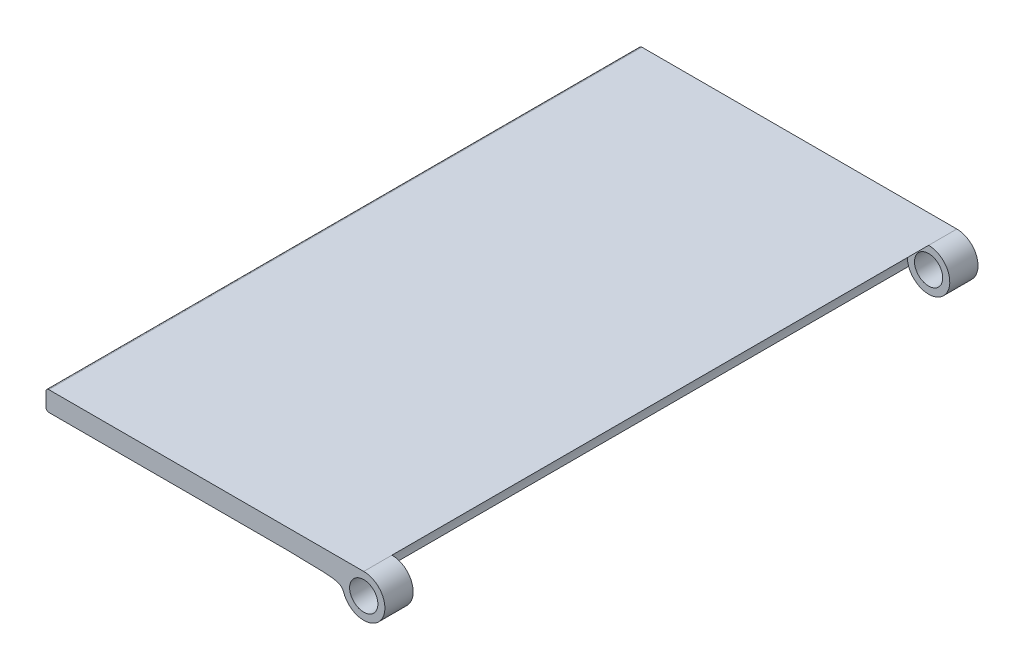
from build123d import *

# Parameters (mm, degrees)
SKETCH_1_R               = 5
EXTRUDE_4_DEPTH          = 210
SKETCH_3_R               = 7.5
CUT_EXTRUDE_3_DEPTH      = 95
CUT_EXTRUDE_3_DEPTH_BACK = 95


with BuildPart() as part:
    # 草图1 → 凸台-拉伸4 (new body)
    with BuildSketch(Plane.XY):
        with BuildLine():
            ThreePointArc((0, 9), (0.292893219, 8.292893219), (1, 8))
            Line((1, 8), (85, 8))
            add(Edge.make_bspline(
                [(85, 8), (102.874129485, 7.751191804), (104.316426779, 7.753525507), (105.428932188, 5)],
                knots=[0, 0, 0, 0, 1, 1, 1, 1], degree=3))
            ThreePointArc((105.428932188, 5), (118.623724357, 3.169872981), (112.5, 15))
            Line((112.5, 15), (1, 15))
            ThreePointArc((1, 15), (0.292893219, 14.707106781), (0, 14))
            Line((0, 14), (0, 9))
        make_face()
        with Locations((112.5, 7.5)):
            Circle(SKETCH_1_R, mode=Mode.SUBTRACT)
    extrude(amount=EXTRUDE_4_DEPTH)

    # 草图3 → 切除-拉伸3 (cut, two sides)
    with BuildSketch(Plane(origin=(0, 0, 105), x_dir=(-1, 0, 0), z_dir=(0, 0, -1))) as cut_extrude_3_sk:
        with Locations((-112.5, 7.5)):
            Circle(SKETCH_3_R)
    extrude(amount=CUT_EXTRUDE_3_DEPTH, mode=Mode.SUBTRACT)
    extrude(cut_extrude_3_sk.sketch, amount=-CUT_EXTRUDE_3_DEPTH_BACK, mode=Mode.SUBTRACT)


solid = part.part
